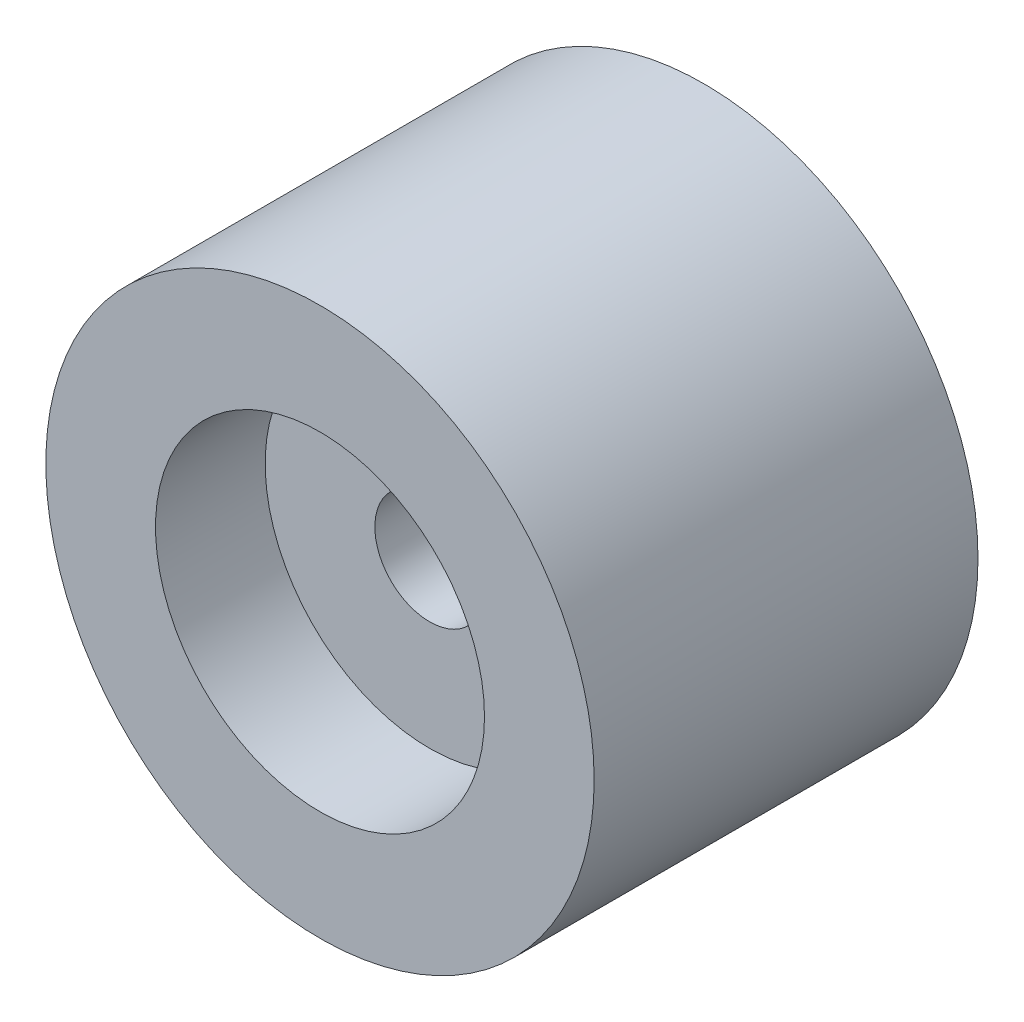
from build123d import *

# Parameters (mm, degrees)
SKETCH1_R           = 100
BOSS_EXTRUDE1_DEPTH = 140
SKETCH2_R           = 60
CUT_EXTRUDE1_DEPTH  = 40
SKETCH4_R           = 20
CUT_EXTRUDE2_DEPTH  = 80


with BuildPart() as part:
    # Sketch1 → Boss-Extrude1 (new body)
    with BuildSketch(Plane.XY):
        Circle(SKETCH1_R)
    extrude(amount=BOSS_EXTRUDE1_DEPTH)

    # Sketch2 → Cut-Extrude1 (cut)
    with BuildSketch(Plane.XY.offset(140)):
        Circle(SKETCH2_R)
    extrude(amount=-CUT_EXTRUDE1_DEPTH, mode=Mode.SUBTRACT)

    # Sketch4 → Cut-Extrude2 (cut)
    with BuildSketch(Plane.XY.offset(100)):
        Circle(SKETCH4_R)
    extrude(amount=-CUT_EXTRUDE2_DEPTH, mode=Mode.SUBTRACT)


solid = part.part
